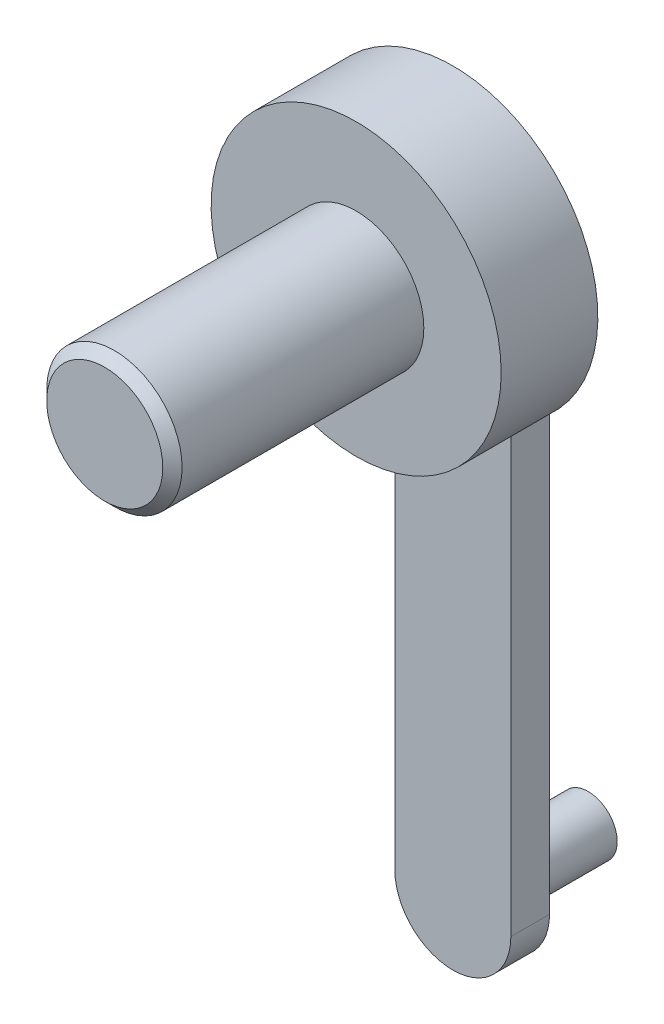
from build123d import *

# Parameters (mm, degrees)
SKETCH1_R           = 7.5
BOSS_EXTRUDE1_DEPTH = 5
SKETCH2_R           = 3.5
BOSS_EXTRUDE2_DEPTH = 13
CHAMFER1_SIZE       = 0.5
BOSS_EXTRUDE3_DEPTH = 2
SKETCH4_R           = 1.5
BOSS_EXTRUDE4_DEPTH = 5


with BuildPart() as part:
    # Sketch1 → Boss-Extrude1 (new body)
    with BuildSketch(Plane.XY):
        Circle(SKETCH1_R)
    extrude(amount=BOSS_EXTRUDE1_DEPTH)

    # Sketch2 → Boss-Extrude2 (add)
    with BuildSketch(Plane.XY.offset(5)):
        Circle(SKETCH2_R)
    extrude(amount=BOSS_EXTRUDE2_DEPTH)

    # Chamfer1
    chamfer1_edges = [part.edges().sort_by_distance(p)[0] for p in [
        (-3.5, 0, 18),
    ]]
    chamfer(chamfer1_edges, length=CHAMFER1_SIZE)

    # Sketch3 → Boss-Extrude3 (add)
    with BuildSketch(Plane(origin=(0, 0, 0), x_dir=(-1, 0, 0), z_dir=(0, 0, -1))):
        with BuildLine():
            Line((3, 0), (3, -30))
            ThreePointArc((3, -30), (0, -33), (-3, -30))
            Line((-3, -30), (-3, 0))
            ThreePointArc((-3, 0), (0, 3), (3, 0))
        make_face()
    extrude(amount=BOSS_EXTRUDE3_DEPTH)

    # Sketch4 → Boss-Extrude4 (add)
    with BuildSketch(Plane(origin=(0, 0, -2), x_dir=(-1, 0, 0), z_dir=(0, 0, -1))):
        with Locations((0, -30)):
            Circle(SKETCH4_R)
    extrude(amount=BOSS_EXTRUDE4_DEPTH)


solid = part.part
